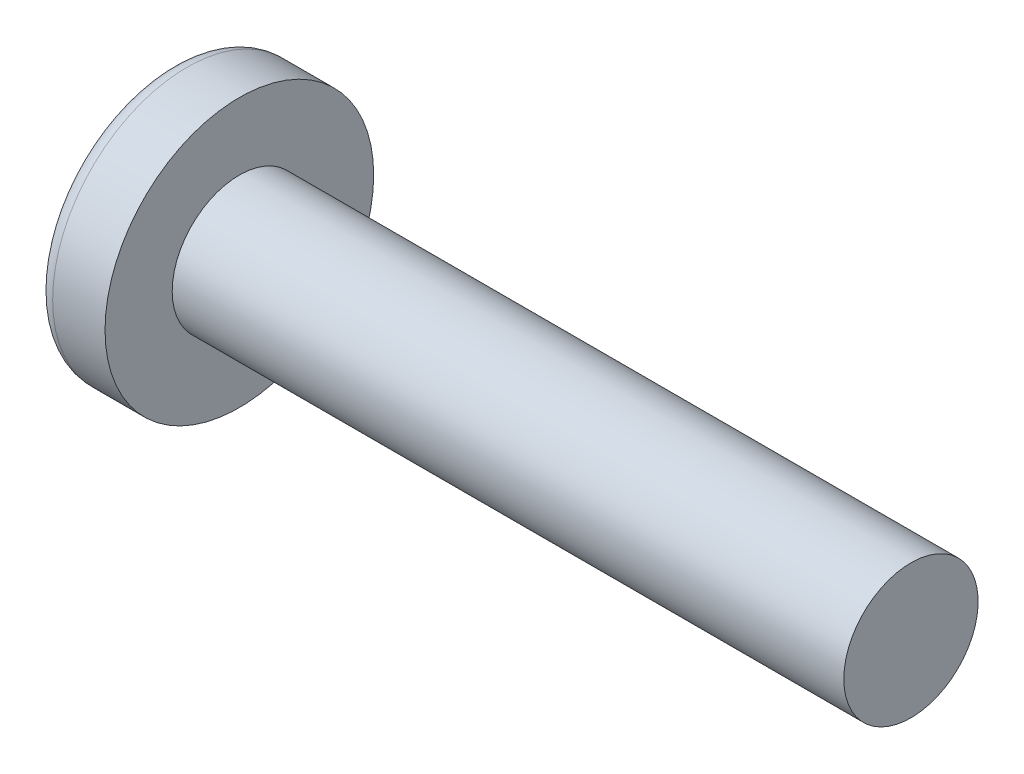
from build123d import *

# Parameters (mm, degrees)
SKETCH3_W         = 0.48
SKETCH3_H         = 1.82
SKETCH4_W         = 0.24
SKETCH4_H         = 0.24
CIRPATTERN1_COUNT = 2
CIRPATTERN1_ANGLE = 90


with BuildPart() as part:
    # BodySke → Base-Revolve (revolve)
    with BuildSketch(Plane.XY):
        with BuildLine():
            Line((1.6, 1), (1.6, 2))
            Line((1.6, 2), (0.820084035, 2))
            ThreePointArc((0.820084035, 2), (0.712029995, 1.974299613), (0.627117876, 1.902702703))
            ThreePointArc((0.627117876, 1.902702703), (0.160820604, 1.001692868), (0, 0))
            Line((0, 0), (11.6, 0))
            Line((11.6, 0), (11.6, 1))
            Line((11.6, 1), (1.6, 1))
        make_face()
    revolve(axis=Axis((-25.4, 0, 0), (1, 0, 0)))

    # Sketch3 → Cut-Loft1 section 0
    with BuildSketch(Plane(origin=(0, 0, 0), x_dir=(0, 0, -1), z_dir=(1, 0, 0))):
        Rectangle(SKETCH3_W, SKETCH3_H)
    # Sketch4 → Cut-Loft1 section 1
    with BuildSketch(Plane(origin=(1.19, 0, 0), x_dir=(0, 0, -1), z_dir=(1, 0, 0))):
        Rectangle(SKETCH4_W, SKETCH4_H)
    cut_loft1 = loft(mode=Mode.SUBTRACT)

    # CirPattern1: Cut-Loft1 ×2 about axis
    cirpattern1_axis = Axis((0, 0, 0), (1, 0, 0))
    for i in range(1, CIRPATTERN1_COUNT):
        add(cut_loft1.rotate(cirpattern1_axis, i * CIRPATTERN1_ANGLE / (CIRPATTERN1_COUNT - 1)), mode=Mode.SUBTRACT)


solid = part.part
